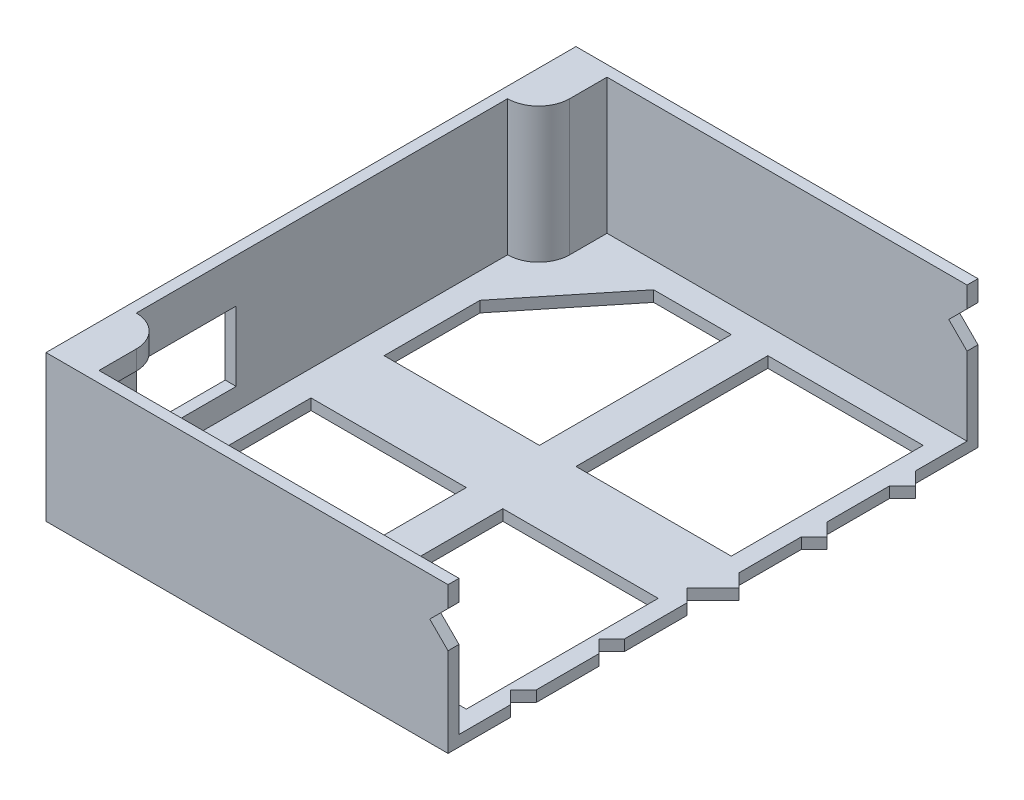
from build123d import *

# Parameters (mm, degrees)
SKETCH1_W               = 220
SKETCH1_H               = 145
SKETCH1_W_2             = 42.5
SKETCH1_H_2             = 52.5
BOSS_EXTRUDE1_DEPTH     = 3
SKETCH2_W               = 220
SKETCH2_H               = 145
BOSS_EXTRUDE2_DEPTH     = 37
SKETCH3_W               = 27.3375
SKETCH3_H               = 19.05
CUT_EXTRUDE1_DEPTH      = 3
SKETCH3_6_W             = 53.975
SKETCH3_6_H             = 31.75
CUT_EXTRUDE2_DEPTH      = 8.5
CUT_EXTRUDE3_DEPTH      = 267.505159425
CUT_EXTRUDE3_DEPTH_BACK = 267.505159425
CUT_EXTRUDE4_DEPTH      = 267.071418984
CUT_EXTRUDE4_DEPTH_BACK = 267.071418984


with BuildPart() as part:
    # Sketch1 → Boss-Extrude1 (new body)
    with BuildSketch(Plane(origin=(0, 0, 0), x_dir=(1, 0, 0), z_dir=(0, 1, 0))):
        with Locations((110, 72.5)):
            Rectangle(SKETCH1_W, SKETCH1_H)
        Polygon((10, 82.5), (52.5, 82.5), (52.5, 135), (31.25, 135), (10, 108.75), align=None, mode=Mode.SUBTRACT)
        with Locations((83.75, 108.75)):
            Rectangle(SKETCH1_W_2, SKETCH1_H_2, mode=Mode.SUBTRACT)
        with Locations((83.75, 36.25)):
            Rectangle(SKETCH1_W_2, SKETCH1_H_2, mode=Mode.SUBTRACT)
        Polygon((10, 36.25), (31.25, 10), (52.5, 10), (52.5, 62.5), (10, 62.5), align=None, mode=Mode.SUBTRACT)
        Polygon((210, 62.5), (210, 36.25), (188.75, 10), (167.5, 10), (167.5, 62.5), align=None, mode=Mode.SUBTRACT)
        with Locations((136.25, 36.25)):
            Rectangle(SKETCH1_W_2, SKETCH1_H_2, mode=Mode.SUBTRACT)
        with Locations((136.25, 108.75)):
            Rectangle(SKETCH1_W_2, SKETCH1_H_2, mode=Mode.SUBTRACT)
        Polygon((210, 108.75), (188.75, 135), (167.5, 135), (167.5, 82.5), (210, 82.5), align=None, mode=Mode.SUBTRACT)
    extrude(amount=BOSS_EXTRUDE1_DEPTH)

    # Sketch2 → Boss-Extrude2 (add)
    with BuildSketch(Plane(origin=(0, 3, 0), x_dir=(1, 0, 0), z_dir=(0, 1, 0))):
        with Locations((110, 72.5)):
            Rectangle(SKETCH2_W, SKETCH2_H)
        with BuildLine():
            Line((3, 123.3), (3, 21.7))
            ThreePointArc((3, 21.7), (9.01040764, 19.21040764), (11.5, 13.2))
            Line((11.5, 13.2), (11.5, 3))
            Line((11.5, 3), (208.5, 3))
            Line((208.5, 3), (208.5, 13.2))
            ThreePointArc((208.5, 13.2), (210.98959236, 19.21040764), (217, 21.7))
            Line((217, 21.7), (217, 123.3))
            ThreePointArc((217, 123.3), (210.98959236, 125.78959236), (208.5, 131.8))
            Line((208.5, 131.8), (208.5, 142))
            Line((208.5, 142), (11.5, 142))
            Line((11.5, 142), (11.5, 131.8))
            ThreePointArc((11.5, 131.8), (9.01040764, 125.78959236), (3, 123.3))
        make_face(mode=Mode.SUBTRACT)
    extrude(amount=BOSS_EXTRUDE2_DEPTH)

    # Sketch3 → Cut-Extrude1 (cut)
    with BuildSketch(Plane.ZY.offset(-3)):
        with Locations((-35.36875, 18.478125)):
            Rectangle(SKETCH3_W, SKETCH3_H)
    extrude(amount=CUT_EXTRUDE1_DEPTH, mode=Mode.SUBTRACT)

    # Sketch3_6 → Cut-Extrude2 (cut)
    with BuildSketch(Plane.ZY.offset(-3)):
        with Locations((-29.9875, 18.875)):
            Rectangle(SKETCH3_6_W, SKETCH3_6_H)
    extrude(amount=-CUT_EXTRUDE2_DEPTH, mode=Mode.SUBTRACT)

    # Sketch7 → Cut-Extrude3 (cut, two sides)
    with BuildSketch(Plane.XY) as cut_extrude3_sk:
        Polygon((110, 40), (110, 34.333333333), (105, 29.333333333), (110, 24.333333333), (110, 18.666666667), (115, 13.666666667), (110, 8.666666667), (110, 3), (220, 3), (220, 40), align=None)
    extrude(amount=CUT_EXTRUDE3_DEPTH, mode=Mode.SUBTRACT)
    extrude(cut_extrude3_sk.sketch, amount=-CUT_EXTRUDE3_DEPTH_BACK, mode=Mode.SUBTRACT)

    # Sketch8 → Cut-Extrude4 (cut, two sides)
    with BuildSketch(Plane(origin=(0, 3, 0), x_dir=(1, 0, 0), z_dir=(0, 1, 0))) as cut_extrude4_sk:
        Polygon((110, 145), (220, 145), (220, 0), (110, 0), (110, 17.095598855), (106.464466094, 20.631132761), (110, 24.166666667), (110, 41.262265521), (106.464466094, 44.797799427), (110, 48.333333333), (110, 65.428932188), (106.464466094, 68.964466094), (113.535533906, 76.035533906), (110, 79.571067812), (110, 96.666666667), (113.535533906, 100.202200573), (110, 103.737734479), (110, 120.833333333), (113.535533906, 124.368867239), (110, 127.904401145), align=None)
    extrude(amount=CUT_EXTRUDE4_DEPTH, mode=Mode.SUBTRACT)
    extrude(cut_extrude4_sk.sketch, amount=-CUT_EXTRUDE4_DEPTH_BACK, mode=Mode.SUBTRACT)


solid = part.part
